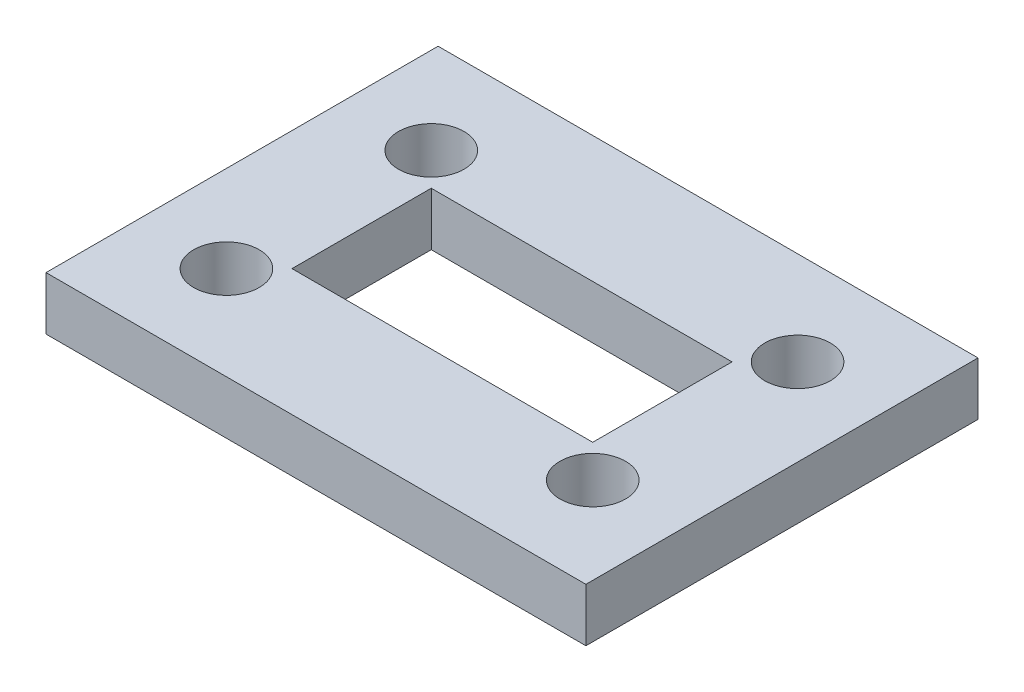
from build123d import *

# Parameters (mm, degrees)
SKETCH3_R           = 8
SKETCH3_W           = 73.4
SKETCH3_H           = 33.99
BOSS_EXTRUDE1_DEPTH = 13


with BuildPart() as part:
    # Sketch3 → Boss-Extrude1 (new body)
    with BuildSketch(Plane(origin=(0, 0, 0), x_dir=(1, 0, 0), z_dir=(0, 1, 0))):
        Polygon((-121.76, 12.85), (-121.76, -10), (-108.58, -10), (-11.18, -10), (-3.18, -10), (10, -10), (10, 62.84), (10, 85.69), (-3.18, 85.69), (-11.18, 85.69), (-108.58, 85.69), (-121.76, 85.69), (-121.76, 62.84), align=None)
        with Locations((-100.58, 12.85)):
            Circle(SKETCH3_R, mode=Mode.SUBTRACT)
        with BuildLine():
            Line((-19.18, 12.85), (-19.18, 20.85))
            Line((-19.18, 20.85), (-11.18, 20.85))
            ThreePointArc((-11.18, 20.85), (-5.523145751, 18.506854249), (-3.18, 12.85))
            ThreePointArc((-3.18, 12.85), (-11.18, 4.85), (-19.18, 12.85))
        make_face(mode=Mode.SUBTRACT)
        with BuildLine():
            Line((-92.58, 54.84), (-100.58, 54.84))
            ThreePointArc((-100.58, 54.84), (-106.236854249, 68.496854249), (-92.58, 62.84))
            Line((-92.58, 62.84), (-92.58, 54.84))
        make_face(mode=Mode.SUBTRACT)
        with Locations((-55.88, 37.845)):
            Rectangle(SKETCH3_W, SKETCH3_H, mode=Mode.SUBTRACT)
        with Locations((-11.18, 62.84)):
            Circle(SKETCH3_R, mode=Mode.SUBTRACT)
        with BuildLine():
            ThreePointArc((-92.58, 62.84), (-94.923145751, 57.183145751), (-100.58, 54.84))
            Line((-100.58, 54.84), (-92.58, 54.84))
            Line((-92.58, 54.84), (-92.58, 62.84))
        make_face()
        with BuildLine():
            Line((-11.18, 20.85), (-19.18, 20.85))
            Line((-19.18, 20.85), (-19.18, 12.85))
            ThreePointArc((-19.18, 12.85), (-16.836854249, 18.506854249), (-11.18, 20.85))
        make_face()
    extrude(amount=BOSS_EXTRUDE1_DEPTH)


solid = part.part
